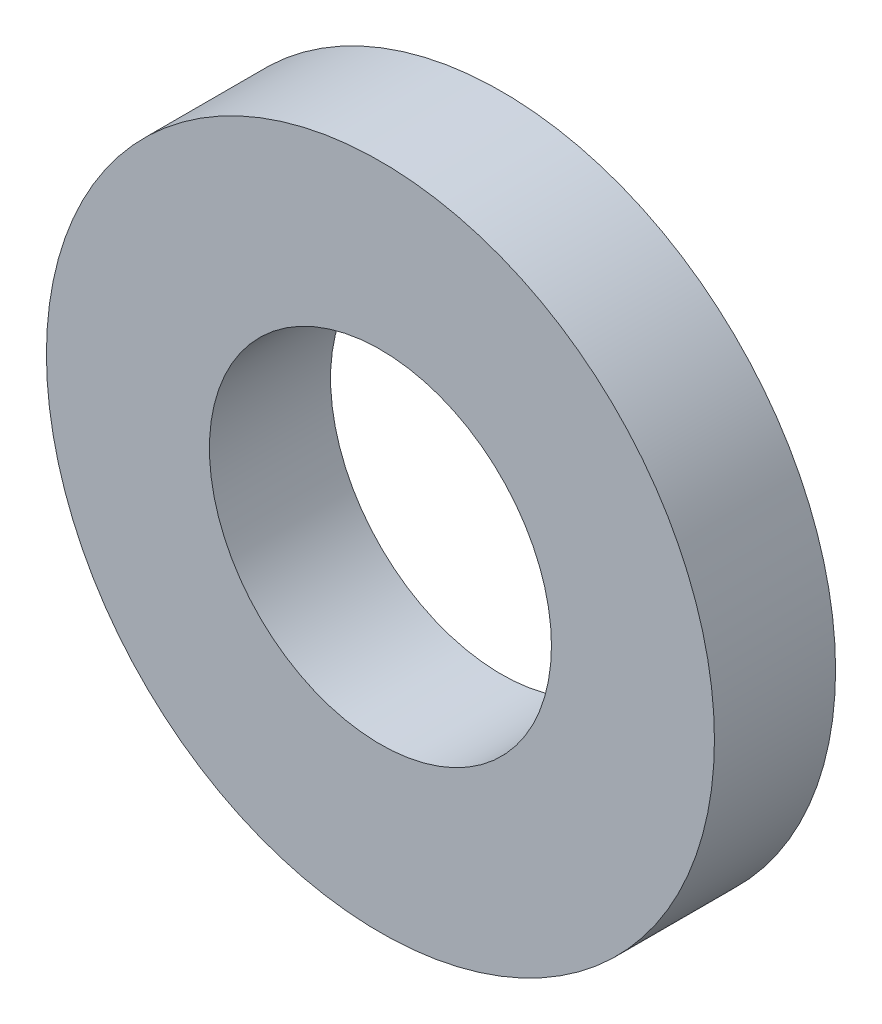
from build123d import *

# Parameters (mm, degrees)
SKETCH1_R      = 4.7625
SKETCH1_R_2    = 2.4384
EXTRUDE1_DEPTH = 1.7272


with BuildPart() as part:
    # Sketch1 → Extrude1 (new body)
    with BuildSketch(Plane.XY):
        Circle(SKETCH1_R)
        Circle(SKETCH1_R_2, mode=Mode.SUBTRACT)
    extrude(amount=-EXTRUDE1_DEPTH)


solid = part.part
